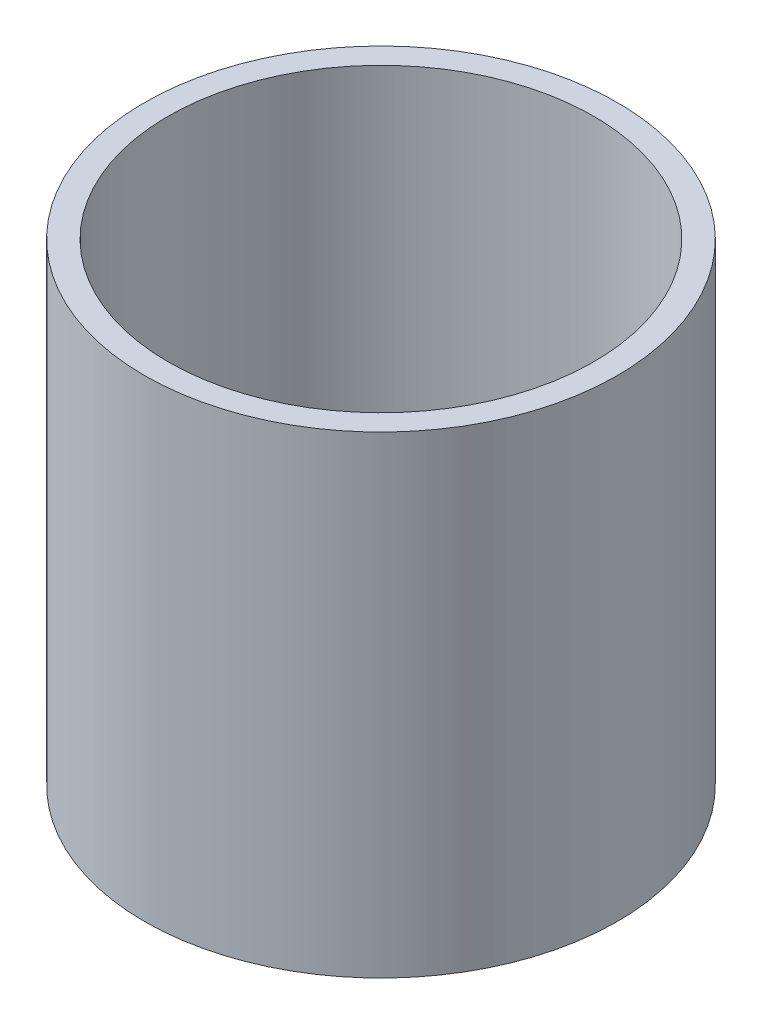
from build123d import *

# Parameters (mm, degrees)
ESBO_O1_R                = 50
ESBO_O1_R_2              = 45
RESSALTO_EXTRUS_O2_DEPTH = 100


with BuildPart() as part:
    # Esboço1 → Ressalto-extrusão2 (new body)
    with BuildSketch(Plane(origin=(0, 0, 0), x_dir=(1, 0, 0), z_dir=(0, 1, 0))):
        Circle(ESBO_O1_R)
        Circle(ESBO_O1_R_2, mode=Mode.SUBTRACT)
    extrude(amount=RESSALTO_EXTRUS_O2_DEPTH)


solid = part.part
